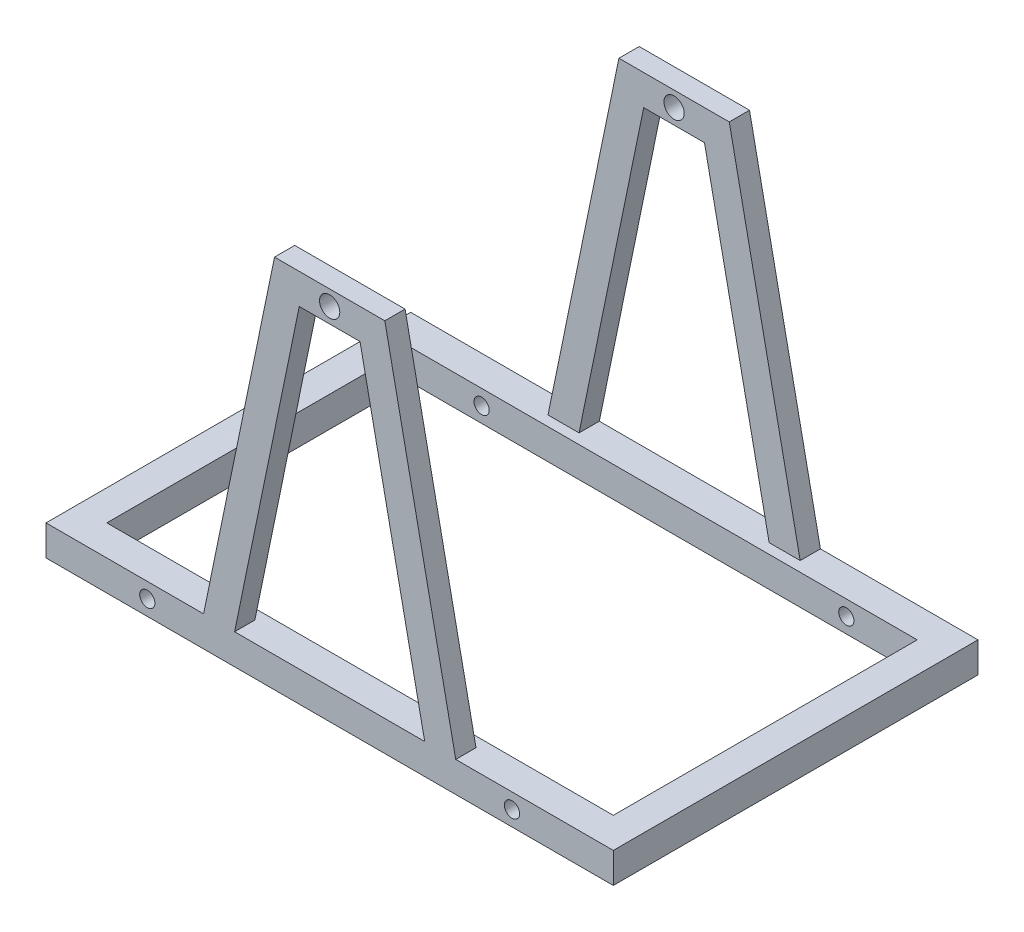
from build123d import *

# Parameters (mm, degrees)
SKETCH1_W           = 560
SKETCH1_H           = 360
SKETCH1_W_2         = 500
SKETCH1_H_2         = 300
EXTRUDE_THIN1_DEPTH = 30
SKETCH2_R           = 7.5
CUT_EXTRUDE1_DEPTH  = 361
EXTRUDE_THIN2_DEPTH = 20
SKETCH4_R           = 10
CUT_EXTRUDE2_DEPTH  = 361


with BuildPart() as part:
    # Sketch1 → Extrude-Thin1 (new body)
    with BuildSketch(Plane(origin=(0, 0, 0), x_dir=(1, 0, 0), z_dir=(0, 1, 0))):
        Rectangle(SKETCH1_W, SKETCH1_H)
        Rectangle(SKETCH1_W_2, SKETCH1_H_2, mode=Mode.SUBTRACT)
    extrude(amount=EXTRUDE_THIN1_DEPTH)

    # Sketch2 → Cut-Extrude1 (cut, through all)
    with BuildSketch(Plane.XY.offset(180)):
        with Locations((-180, 15)):
            Circle(SKETCH2_R)
        with Locations((180, 15)):
            Circle(SKETCH2_R)
    extrude(amount=-CUT_EXTRUDE1_DEPTH, mode=Mode.SUBTRACT)

    # Sketch3 → Extrude-Thin2 (add)
    with BuildSketch(Plane.XY.offset(180)):
        Polygon((-100, 0), (-30, 340), (30, 340), (100, 0), (129.383711298, 6.04958762), (54.452744043, 370), (-54.452744043, 370), (-129.383711298, 6.04958762), align=None)
    extrude_thin2 = extrude(amount=-EXTRUDE_THIN2_DEPTH)

    # Sketch4 → Cut-Extrude2 (cut, through all)
    with BuildSketch(Plane.XY.offset(180)):
        with Locations((0, 355)):
            Circle(SKETCH4_R)
    cut_extrude2 = extrude(amount=-CUT_EXTRUDE2_DEPTH, mode=Mode.SUBTRACT)

    # Mirror1: Extrude-Thin2, Cut-Extrude2 across plane
    add(extrude_thin2.mirror(Plane.XY))
    add(cut_extrude2.mirror(Plane.XY), mode=Mode.SUBTRACT)


solid = part.part
